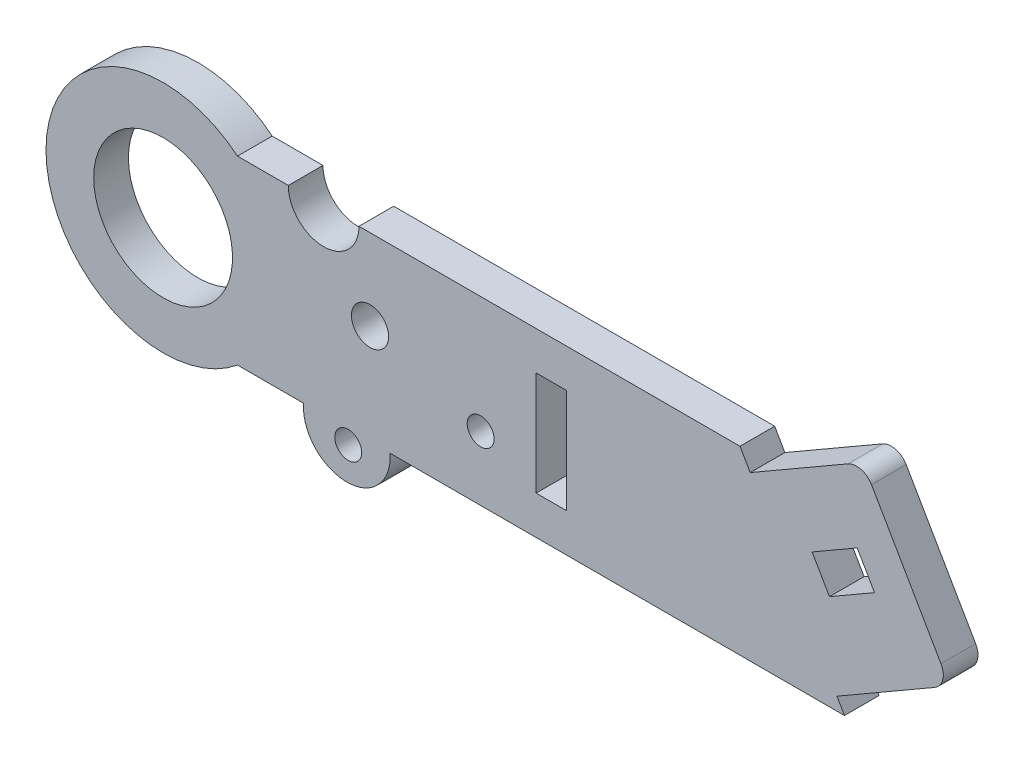
from build123d import *

# Parameters (mm, degrees)
AUFSATZ_LINEAR_AUSTRAGEN1_DEPTH = 4
SCHNITT_LINEAR_AUSTRAGEN1_REACH = 6
SKIZZE2_R                       = 8
SKIZZE2_R_2                     = 2.141321697
SCHNITT_LINEAR_START            = -4
SCHNITT_LINEAR_AUSTRAGEN2_DEPTH = 4
AUFSATZ_LINEAR_AUSTRAGEN3_DEPTH = 4
SCHNITT_LINEAR_AUSTRAGEN3_REACH = 6
SKIZZE5_W                       = 3.5
SKIZZE5_H                       = 12
AUFSATZ_LINEAR_AUSTRAGEN4_DEPTH = 4
SKIZZE7_R                       = 1.55
SCHNITT_LINEAR_AUSTRAGEN4_DEPTH = 10


with BuildPart() as part:
    # Skizze1 → Aufsatz-Linear austragen1 (new body)
    with BuildSketch(Plane.XY):
        with BuildLine():
            Line((8.570550732, -10.430515814), (-71.429449268, -10.430515814))
            ThreePointArc((-71.429449268, -10.430515814), (-93.5, 0), (-71.429449268, 10.430515814))
            Line((-71.429449268, 10.430515814), (-65.575289804, 10.430515814))
            ThreePointArc((-65.575289804, 10.430515814), (-61.49939442, 6.35462043), (-57.423499036, 10.430515814))
            Line((-57.423499036, 10.430515814), (8.570550732, 10.430515814))
            ThreePointArc((8.570550732, 10.430515814), (19.001066546, 0), (8.570550732, -10.430515814))
        make_face()
    extrude(amount=AUFSATZ_LINEAR_AUSTRAGEN1_DEPTH)

    # Skizze2 → Schnitt-Linear austragen1 (cut, up to next)
    with BuildSketch(Plane.XY.offset(4), mode=Mode.PRIVATE) as schnitt_linear_austragen1_sk1:
        with Locations((-80, 0)):
            Circle(SKIZZE2_R)
    schnitt_linear_austragen1_tool1 = extrude(schnitt_linear_austragen1_sk1.sketch, amount=-SCHNITT_LINEAR_AUSTRAGEN1_REACH, mode=Mode.PRIVATE) & part.part
    add(schnitt_linear_austragen1_tool1.solids().sort_by_distance((-80, 0, 4))[0], mode=Mode.SUBTRACT)
    # Skizze2 → Schnitt-Linear austragen1 (cut, up to next)
    with BuildSketch(Plane.XY.offset(4), mode=Mode.PRIVATE) as schnitt_linear_austragen1_sk2:
        with Locations((-56.152824314, 1.105869461)):
            Circle(SKIZZE2_R_2)
    schnitt_linear_austragen1_tool2 = extrude(schnitt_linear_austragen1_sk2.sketch, amount=-SCHNITT_LINEAR_AUSTRAGEN1_REACH, mode=Mode.PRIVATE) & part.part
    add(schnitt_linear_austragen1_tool2.solids().sort_by_distance((-56.152824, 1.105869, 4))[0], mode=Mode.SUBTRACT)
    # Skizze2 → Schnitt-Linear austragen1 (cut, up to next)
    with BuildSketch(Plane.XY.offset(4), mode=Mode.PRIVATE) as schnitt_linear_austragen1_sk3:
        Polygon((-5.196152423, 4.033585801), (0, 7.033585801), (2, 3.569484186), (-3.196152423, 0.569484186), align=None)
    schnitt_linear_austragen1_tool3 = extrude(schnitt_linear_austragen1_sk3.sketch, amount=-SCHNITT_LINEAR_AUSTRAGEN1_REACH, mode=Mode.PRIVATE) & part.part
    add(schnitt_linear_austragen1_tool3.solids().sort_by_distance((-1.598076, 3.801535, 4))[0], mode=Mode.SUBTRACT)

    # Skizze3 → Schnitt-Linear austragen2 (cut)
    with BuildSketch(Plane.XY.offset(4).offset(SCHNITT_LINEAR_START)):
        Polygon((12.98673942, 30.628285162), (33.019811303, -4.070013171), (4.402698179, -20.592111136), (-2.330127019, -8.930515814), (8.92820323, -2.430515814), (-1.07179677, 14.889992262), (-12.330127019, 8.389992262), (-15.630373703, 14.106187196), align=None)
    extrude(amount=SCHNITT_LINEAR_AUSTRAGEN2_DEPTH, mode=Mode.SUBTRACT)

    # Skizze4 → Aufsatz-Linear austragen3 (add)
    with BuildSketch(Plane.XY):
        with BuildLine():
            Line((-8.795836552, 10.430515814), (-1.07179677, 14.889992262))
            ThreePointArc((-1.07179677, 14.889992262), (0.435735022, 15.092552947), (1.649755119, 14.176126114))
            Line((1.649755119, 14.176126114), (9.66025479, 0.301533691))
            ThreePointArc((9.66025479, 0.301533691), (9.860054688, -1.216103823), (8.92820323, -2.430515814))
            Line((8.92820323, -2.430515814), (1.502883158, 10.430515814))
            Line((1.502883158, 10.430515814), (-8.795836552, 10.430515814))
        make_face()
    extrude(amount=AUFSATZ_LINEAR_AUSTRAGEN3_DEPTH)

    # Skizze5 → Schnitt-Linear austragen3 (cut, up to next)
    with BuildSketch(Plane.XY.offset(4), mode=Mode.PRIVATE) as schnitt_linear_austragen3_sk1:
        with Locations((-35.258223841, 0)):
            Rectangle(SKIZZE5_W, SKIZZE5_H)
    schnitt_linear_austragen3_tool1 = extrude(schnitt_linear_austragen3_sk1.sketch, amount=-SCHNITT_LINEAR_AUSTRAGEN3_REACH, mode=Mode.PRIVATE) & part.part
    add(schnitt_linear_austragen3_tool1.solids().sort_by_distance((-35.258224, 0, 4))[0], mode=Mode.SUBTRACT)

    # Skizze6 → Aufsatz-Linear austragen4 (add)
    with BuildSketch(Plane.XY.offset(4)):
        with BuildLine():
            Line((-63.811678178, -10.430515814), (-53.840299994, -10.430515814))
            ThreePointArc((-53.840299994, -10.430515814), (-58.825989086, -15.808542635), (-63.811678178, -10.430515814))
        make_face()
    extrude(amount=-AUFSATZ_LINEAR_AUSTRAGEN4_DEPTH)

    # Skizze7 → Schnitt-Linear austragen4 (cut)
    with BuildSketch(Plane.XY.offset(4)):
        with Locations((-58.659847502, -12.012547734)):
            Circle(SKIZZE7_R)
        with Locations((-43.4, -3.025056359)):
            Circle(SKIZZE7_R)
    extrude(amount=-SCHNITT_LINEAR_AUSTRAGEN4_DEPTH, mode=Mode.SUBTRACT)


solid = part.part
